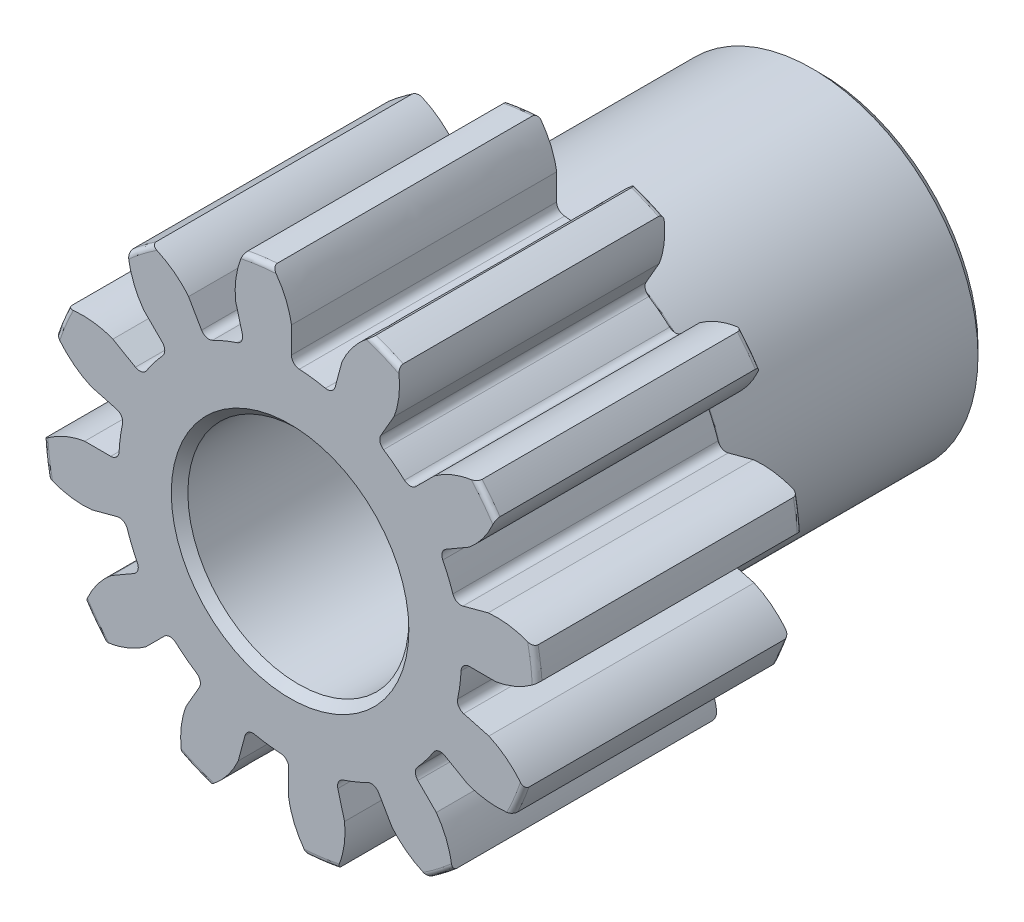
from build123d import *

# Parameters (mm, degrees)
SKETCH1_R                = 8.89
BOSS_EXTRUDE1_DEPTH      = 9.525
SKETCH2_W                = 9.525
SKETCH2_H                = 5.953125
REVOLVE1_ANGLE           = 360
FILLET2_R                = 0.1778
CUT_EXTRUDE1_DEPTH       = 20.05
FILLET1_R                = 0.2992374
CIRPATTERN1_COUNT        = 12
FILLET1_OF_CIRPATTERN1_R = 0.2992374
SKETCH5_R                = 3.96875
CUT_EXTRUDE2_DEPTH       = 20.05
CHAMFER1_SIZE            = 0.29765625


with BuildPart() as part:
    # Sketch1 → Boss-Extrude1 (new body)
    with BuildSketch(Plane.XY):
        Circle(SKETCH1_R)
    extrude(amount=-BOSS_EXTRUDE1_DEPTH)

    # Sketch2 → Revolve1 (revolve, symmetric)
    with BuildSketch(Plane(origin=(0, 0, 0), x_dir=(0, 0, -1), z_dir=(1, 0, 0))) as revolve1_sk:
        with Locations((14.2875, 2.9765625)):
            Rectangle(SKETCH2_W, SKETCH2_H)
    revolve(axis=Axis((0, 0, -9.525), (0, 0, -1)), revolution_arc=REVOLVE1_ANGLE / 2)
    revolve(revolve1_sk.sketch, axis=Axis((0, 0, -9.525), (0, 0, 1)), revolution_arc=REVOLVE1_ANGLE / 2)

    # Fillet2
    fillet2_edges = [part.edges().sort_by_distance(p)[0] for p in [
        (-8.89, 0, 0),
        (-8.89, 0, -9.525),
        (0, -5.953125, -9.525),
    ]]
    fillet(fillet2_edges, radius=FILLET2_R)

    # Sketch4 → Cut-Extrude1 (cut, through all)
    with BuildSketch(Plane.XY):
        with BuildLine():
            Line((0.04830876, 7.377126848), (0.04830876, 6.150420281))
            ThreePointArc((0.04830876, 6.150420281), (0.80281757, 6.097990433), (1.54518687, 5.953352073))
            Line((1.54518687, 5.953352073), (1.862682618, 7.138259433))
            add(Edge.make_bspline(
                [(2.921760286, 8.411131642), (2.200093057, 7.899390383), (1.862682618, 7.138259433)],
                knots=[0, 0, 0, 1, 1, 1], degree=2))
            ThreePointArc((2.921760286, 8.411131642), (1.162226994, 8.82796959), (-0.645237222, 8.880736884))
            add(Edge.make_bspline(
                [(-0.645237222, 8.880736884), (-0.080609008, 8.199651217), (0.04830876, 7.377126848)],
                knots=[0, 0, 0, 1, 1, 1], degree=2))
        make_face()
    cut_extrude1 = extrude(amount=-CUT_EXTRUDE1_DEPTH, mode=Mode.SUBTRACT)

    # Fillet1
    fillet1_edges = [part.edges().sort_by_distance(p)[0] for p in [
        (1.54518687, 5.953352073, -4.7625),
        (0.04830876, 6.150420281, -4.7625),
    ]]
    fillet(fillet1_edges, radius=FILLET1_R)

    # CirPattern1: Cut-Extrude1 ×12 about axis
    cirpattern1_axis = Axis((0, 0, -9.525), (0, 0, 1))
    for i in range(1, CIRPATTERN1_COUNT):
        add(cut_extrude1.rotate(cirpattern1_axis, i * 360 / CIRPATTERN1_COUNT), mode=Mode.SUBTRACT)

    # Fillet1 of CirPattern1
    fillet1_of_cirpattern1_edges = [part.edges().sort_by_distance(p)[0] for p in [
        (-1.638504953, 5.928347568, -4.7625),
        (-3.033373527, 5.350574587, -4.7625),
        (-4.383160698, 4.31484712, -4.7625),
        (-5.302265828, 3.117046754, -4.7625),
        (-5.953352073, 1.54518687, -4.7625),
        (-6.150420281, 0.04830876, -4.7625),
        (-5.928347568, -1.638504953, -4.7625),
        (-5.350574587, -3.033373527, -4.7625),
        (-4.31484712, -4.383160698, -4.7625),
        (-3.117046754, -5.302265828, -4.7625),
        (-1.54518687, -5.953352073, -4.7625),
        (-0.04830876, -6.150420281, -4.7625),
        (1.638504953, -5.928347568, -4.7625),
        (3.033373527, -5.350574587, -4.7625),
        (4.383160698, -4.31484712, -4.7625),
        (5.302265828, -3.117046754, -4.7625),
        (5.953352073, -1.54518687, -4.7625),
        (6.150420281, -0.04830876, -4.7625),
        (5.928347568, 1.638504953, -4.7625),
        (5.350574587, 3.033373527, -4.7625),
        (4.31484712, 4.383160698, -4.7625),
        (3.117046754, 5.302265828, -4.7625),
    ]]
    fillet(fillet1_of_cirpattern1_edges, radius=FILLET1_OF_CIRPATTERN1_R)

    # Sketch5 → Cut-Extrude2 (cut, through all)
    with BuildSketch(Plane.XY):
        Circle(SKETCH5_R)
    extrude(amount=-CUT_EXTRUDE2_DEPTH, mode=Mode.SUBTRACT)

    # Chamfer1
    chamfer1_edges = [part.edges().sort_by_distance(p)[0] for p in [
        (0, -5.953125, -19.05),
        (-3.96875, 0, -19.05),
        (-3.96875, 0, 0),
    ]]
    chamfer(chamfer1_edges, length=CHAMFER1_SIZE)


solid = part.part
